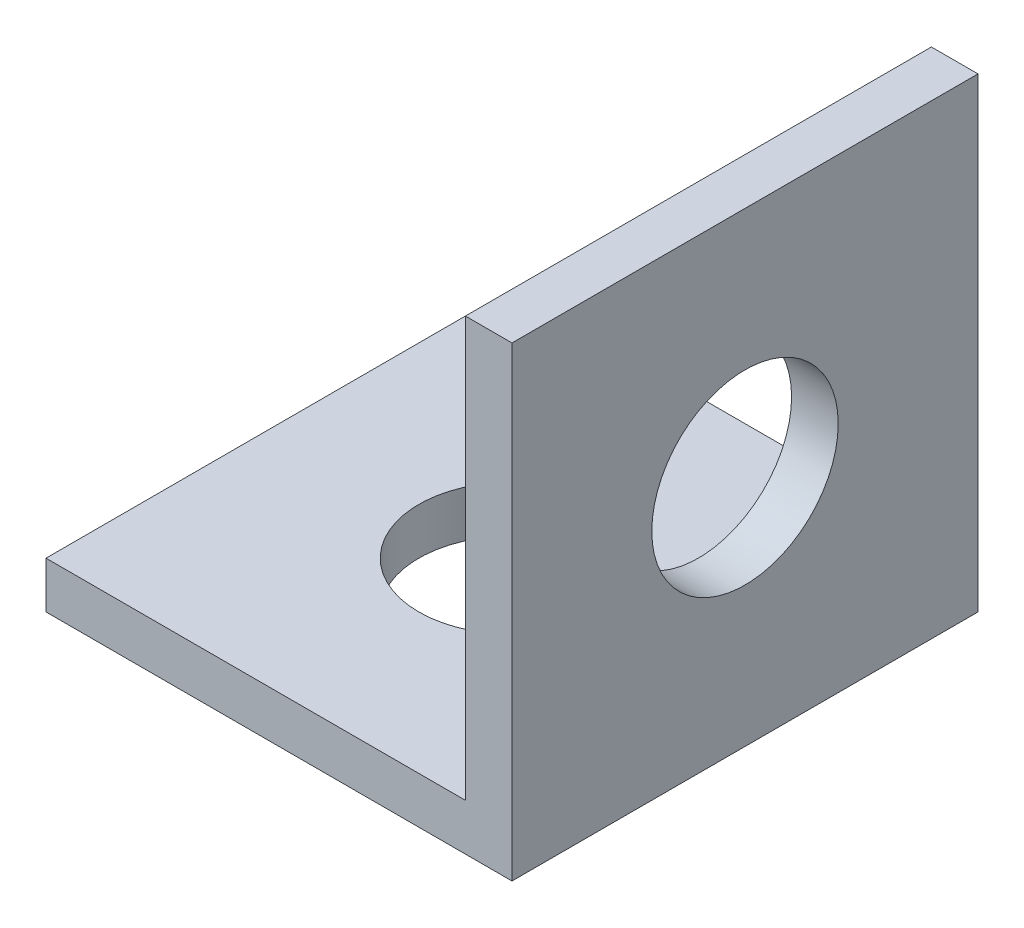
from build123d import *

# Parameters (mm, degrees)
ESQUISSE1_W      = 10
ESQUISSE1_H      = 10
ESQUISSE1_R      = 2
EXTRUSION1_DEPTH = 1
ESQUISSE2_W      = 1
ESQUISSE2_H      = 10
EXTRUSION2_DEPTH = 9
EXTRUSION3_REACH = 12
ESQUISSE3_R      = 2


with BuildPart() as part:
    # Esquisse1 → Extrusion1 (new body)
    with BuildSketch(Plane(origin=(0, 0, 0), x_dir=(1, 0, 0), z_dir=(0, 1, 0))):
        with Locations((5, 5)):
            Rectangle(ESQUISSE1_W, ESQUISSE1_H)
        with Locations((5, 5)):
            Circle(ESQUISSE1_R, mode=Mode.SUBTRACT)
    extrude(amount=EXTRUSION1_DEPTH)

    # Esquisse2 → Extrusion2 (add)
    with BuildSketch(Plane(origin=(0, 1, 0), x_dir=(1, 0, 0), z_dir=(0, 1, 0))):
        with Locations((9.5, 5)):
            Rectangle(ESQUISSE2_W, ESQUISSE2_H)
    extrude(amount=EXTRUSION2_DEPTH)

    # Esquisse3 → Extrusion3 (cut, up to next)
    with BuildSketch(Plane(origin=(10, 0, 0), x_dir=(0, 0, -1), z_dir=(1, 0, 0)), mode=Mode.PRIVATE) as extrusion3_sk1:
        with Locations((5, 5)):
            Circle(ESQUISSE3_R)
    extrusion3_tool1 = extrude(extrusion3_sk1.sketch, amount=-EXTRUSION3_REACH, mode=Mode.PRIVATE) & part.part
    add(extrusion3_tool1.solids().sort_by_distance((10, 5, -5))[0], mode=Mode.SUBTRACT)


solid = part.part
